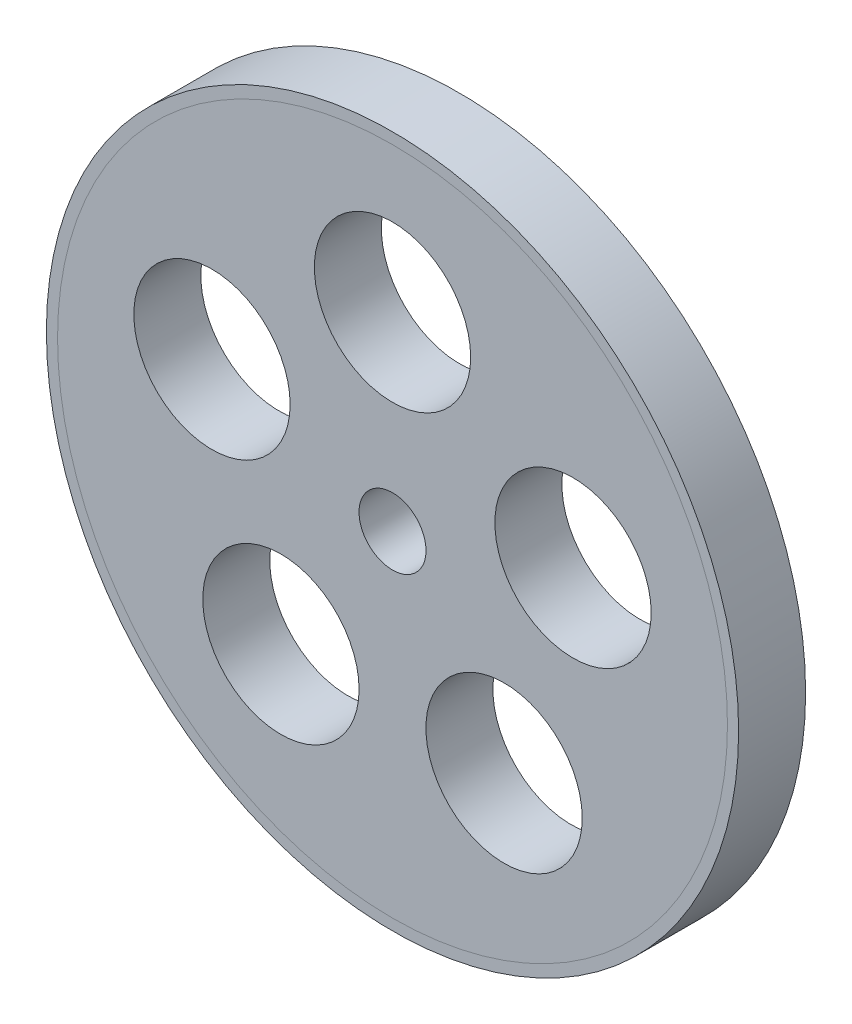
from build123d import *

# Parameters (mm, degrees)
SKETCH1_R               = 15
SKETCH1_R_2             = 1.5
BOSS_EXTRUDE1_DEPTH     = 3
SKETCH4_R               = 3.5
CUT_EXTRUDE1_DEPTH      = 1
CUT_EXTRUDE1_DEPTH_BACK = 4
SKETCH2_W               = 0.5
SKETCH2_H               = 3


with BuildPart() as part:
    # Sketch1 → Boss-Extrude1 (new body)
    with BuildSketch(Plane.XY):
        Circle(SKETCH1_R)
        Circle(SKETCH1_R_2, mode=Mode.SUBTRACT)
    extrude(amount=BOSS_EXTRUDE1_DEPTH)

    # Sketch4 → Cut-Extrude1 (cut, two sides)
    with BuildSketch(Plane.XY.offset(3)) as cut_extrude1_sk:
        with Locations((0, 8.5)):
            Circle(SKETCH4_R)
        with Locations((8.083980389, 2.626644452)):
            Circle(SKETCH4_R)
        with Locations((4.996174644, -6.876644452)):
            Circle(SKETCH4_R)
        with Locations((-4.996174644, -6.876644452)):
            Circle(SKETCH4_R)
        with Locations((-8.083980389, 2.626644452)):
            Circle(SKETCH4_R)
    extrude(amount=CUT_EXTRUDE1_DEPTH, mode=Mode.SUBTRACT)
    extrude(cut_extrude1_sk.sketch, amount=-CUT_EXTRUDE1_DEPTH_BACK, mode=Mode.SUBTRACT)


with BuildPart() as body_2:
    # Sketch2 → Revolve1 (revolve)
    with BuildSketch(Plane(origin=(0, 0, 0), x_dir=(1, 0, 0), z_dir=(0, 1, 0))):
        with Locations((-15.25, -1.5)):
            Rectangle(SKETCH2_W, SKETCH2_H)
    revolve(axis=Axis((0, 0, 0), (0, 0, 1)))


solid = Compound([part.part, body_2.part])
